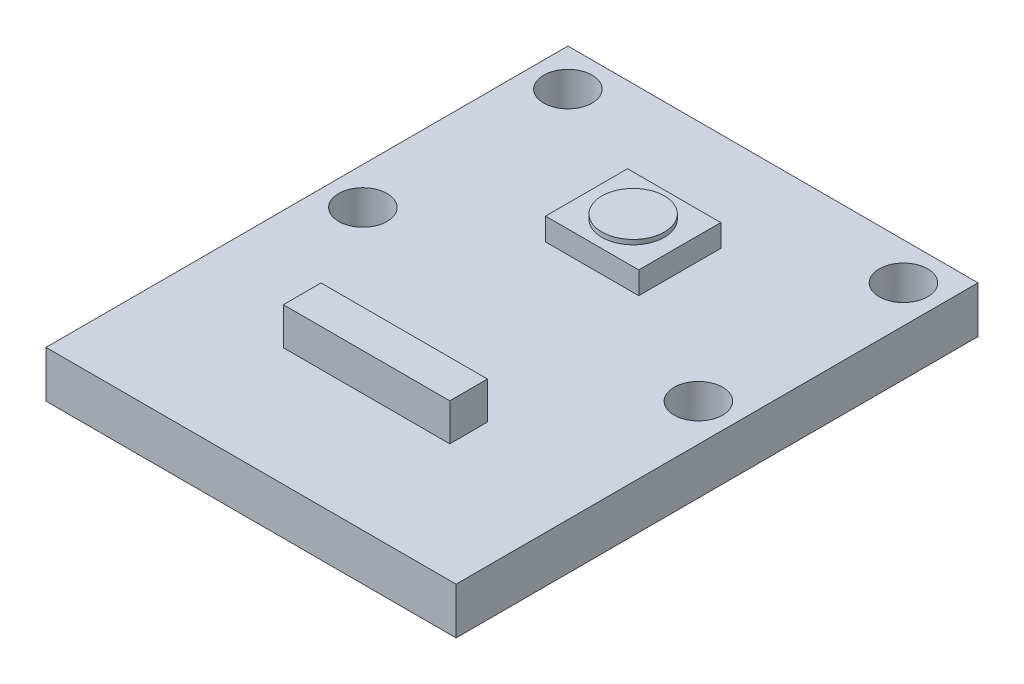
from build123d import *

# Parameters (mm, degrees)
SKETCH1_W                 = 22
SKETCH1_H                 = 15
BOSS_EXTRUDE1_DEPTH       = 2.5
F_1_0MM_DOWEL_HOLE1_D     = 2.6
F_1_0MM_DOWEL_HOLE1_DEPTH = 6.35
F_1_0MM_DOWEL_HOLE1_TIP   = 0.781118805
SKETCH4_W                 = 5
SKETCH4_H                 = 4.4
BOSS_EXTRUDE2_DEPTH       = 1.2
SKETCH5_W                 = 22
SKETCH5_H                 = 13
BOSS_EXTRUDE3_DEPTH       = 2.5
SKETCH6_W                 = 8.928834932
SKETCH6_H                 = 2.022342955
BOSS_EXTRUDE4_DEPTH       = 2
SKETCH7_R                 = 1.677550445
BOSS_EXTRUDE5_DEPTH       = 0.25


with BuildPart() as part:
    # Sketch1 → Boss-Extrude1 (new body)
    with BuildSketch(Plane(origin=(0, 0, 0), x_dir=(1, 0, 0), z_dir=(0, 1, 0))):
        Rectangle(SKETCH1_W, SKETCH1_H)
    extrude(amount=BOSS_EXTRUDE1_DEPTH)

    # Ø1.0mm Dowel Hole1
    with Locations(Plane(origin=(0, 2.5, 0), x_dir=(1, 0, 0), z_dir=(0, 1, 0))):
        with Locations((-9, 5.5), (9, 5.5), (9, -5.5), (-9, -5.5)):
            Hole(F_1_0MM_DOWEL_HOLE1_D / 2, depth=F_1_0MM_DOWEL_HOLE1_DEPTH)
            with Locations((0, 0, -(F_1_0MM_DOWEL_HOLE1_DEPTH + F_1_0MM_DOWEL_HOLE1_TIP / 2))):  # 118° drill point
                Cone(0, F_1_0MM_DOWEL_HOLE1_D / 2, F_1_0MM_DOWEL_HOLE1_TIP, mode=Mode.SUBTRACT)

    # Sketch4 → Boss-Extrude2 (add)
    with BuildSketch(Plane(origin=(0, 2.5, 0), x_dir=(1, 0, 0), z_dir=(0, 1, 0))):
        Rectangle(SKETCH4_W, SKETCH4_H)
    extrude(amount=BOSS_EXTRUDE2_DEPTH)

    # Sketch5 → Boss-Extrude3 (add)
    with BuildSketch(Plane(origin=(0, 2.5, 0), x_dir=(1, 0, 0), z_dir=(0, 1, 0))):
        with Locations((0, -14)):
            Rectangle(SKETCH5_W, SKETCH5_H)
    extrude(amount=-BOSS_EXTRUDE3_DEPTH)

    # Sketch6 → Boss-Extrude4 (add)
    with BuildSketch(Plane(origin=(0, 2.5, 0), x_dir=(1, 0, 0), z_dir=(0, 1, 0))):
        with Locations((-0.152629657, -13.139390077)):
            Rectangle(SKETCH6_W, SKETCH6_H)
    extrude(amount=BOSS_EXTRUDE4_DEPTH)

    # Sketch7 → Boss-Extrude5 (add)
    with BuildSketch(Plane(origin=(0, 3.7, 0), x_dir=(1, 0, 0), z_dir=(0, 1, 0))):
        Circle(SKETCH7_R)
    extrude(amount=BOSS_EXTRUDE5_DEPTH)


solid = part.part
